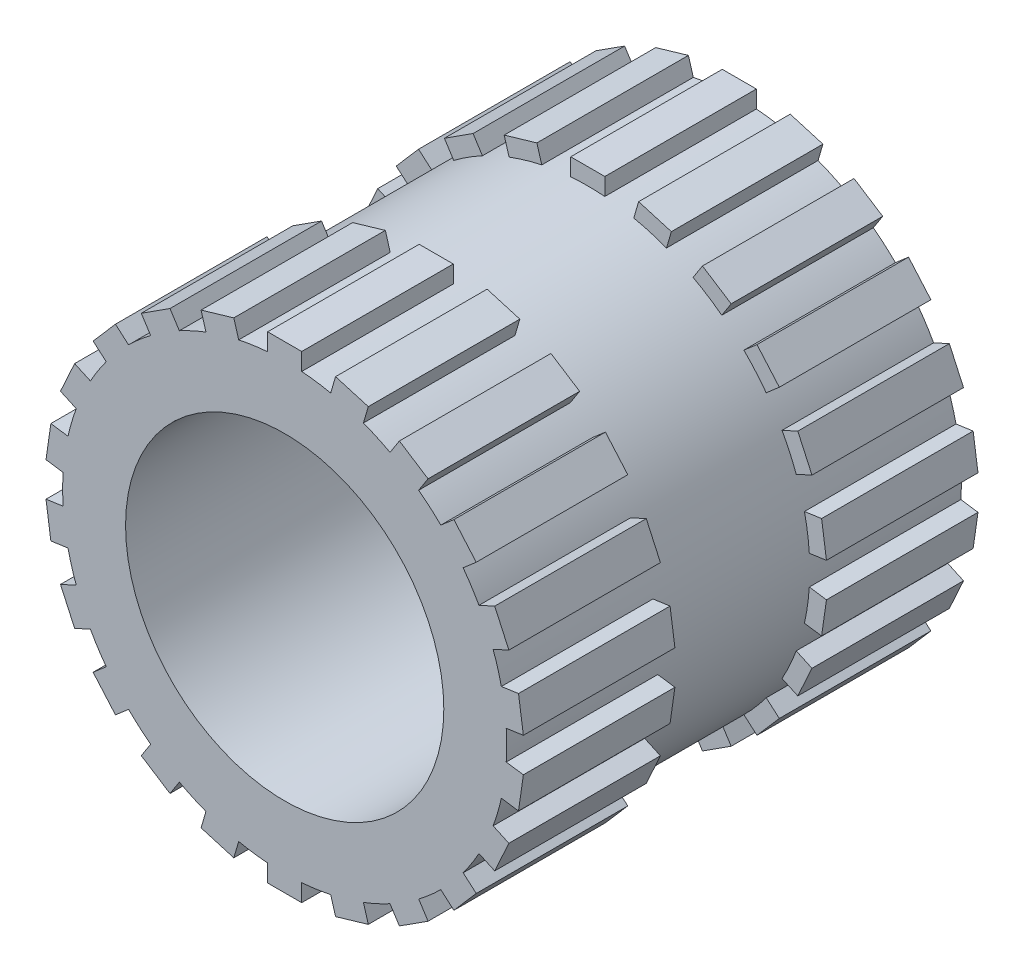
from build123d import *

# Parameters (mm, degrees)
SKETCH1_R                   = 2.93
BOSS_EXTRUDE1_DEPTH         = 3
TAP_DRILL_FOR_M5X0_8_TAP1_D = 4.2
BOSS_EXTRUDE2_DEPTH         = 2
CIRPATTERN1_COUNT           = 22
MIRROR1_COPY_1_DEPTH        = 2
MIRROR1_COPY_2_DEPTH        = 2
MIRROR1_COPY_3_DEPTH        = 2
MIRROR1_COPY_4_DEPTH        = 2
MIRROR1_COPY_5_DEPTH        = 2
MIRROR1_COPY_6_DEPTH        = 2
MIRROR1_COPY_7_DEPTH        = 2
MIRROR1_COPY_8_DEPTH        = 2
MIRROR1_COPY_9_DEPTH        = 2
MIRROR1_COPY_10_DEPTH       = 2
MIRROR1_COPY_11_DEPTH       = 2
MIRROR1_COPY_12_DEPTH       = 2
MIRROR1_COPY_13_DEPTH       = 2
MIRROR1_COPY_14_DEPTH       = 2
MIRROR1_COPY_15_DEPTH       = 2
MIRROR1_COPY_16_DEPTH       = 2
MIRROR1_COPY_17_DEPTH       = 2
MIRROR1_COPY_18_DEPTH       = 2
MIRROR1_COPY_19_DEPTH       = 2
MIRROR1_COPY_20_DEPTH       = 2
MIRROR1_COPY_21_DEPTH       = 2


with BuildPart() as part:
    # Sketch1 → Boss-Extrude1 (new body, symmetric)
    with BuildSketch(Plane.XY):
        Circle(SKETCH1_R)
    extrude(amount=BOSS_EXTRUDE1_DEPTH, both=True)

    # Tap Drill for M5x0.8 Tap1 (through all)
    with Locations(Plane.XY.offset(3)):
        with Locations((0, 0)):
            Hole(TAP_DRILL_FOR_M5X0_8_TAP1_D / 2)

    # Sketch4 → Boss-Extrude2 (add)
    with BuildSketch(Plane.XY.offset(3)):
        with BuildLine():
            Line((-0.225, 3.15), (0.225, 3.15))
            Line((0.225, 3.15), (0.225, 2.921348148))
            ThreePointArc((0.225, 2.921348148), (0, 2.93), (-0.225, 2.921348148))
            Line((-0.225, 2.921348148), (-0.225, 3.15))
        make_face()
    boss_extrude2 = extrude(amount=-BOSS_EXTRUDE2_DEPTH)

    # CirPattern1: Boss-Extrude2 ×22 about axis
    cirpattern1_axis = Axis((0, 0, 0), (0, 0, 1))
    for i in range(1, CIRPATTERN1_COUNT):
        add(boss_extrude2.rotate(cirpattern1_axis, i * 360 / CIRPATTERN1_COUNT))

    # Mirror1: Boss-Extrude2 across plane
    add(boss_extrude2.mirror(Plane.XY))

    # Mirror1 copy 1 sketch → Mirror1 copy 1 (add)
    with BuildSketch(Plane(origin=(0, 0, -3), x_dir=(0.959492974, 0.281732557, 0), z_dir=(0, 0, -1))):
        with BuildLine():
            Line((-0.225, -3.15), (0.225, -3.15))
            Line((0.225, -3.15), (0.225, -2.921348148))
            ThreePointArc((0.225, -2.921348148), (0, -2.93), (-0.225, -2.921348148))
            Line((-0.225, -2.921348148), (-0.225, -3.15))
        make_face()
    extrude(amount=-MIRROR1_COPY_1_DEPTH)

    # Mirror1 copy 2 sketch → Mirror1 copy 2 (add)
    with BuildSketch(Plane(origin=(0, 0, -3), x_dir=(0.841253533, 0.540640817, 0), z_dir=(0, 0, -1))):
        with BuildLine():
            Line((-0.225, -3.15), (0.225, -3.15))
            Line((0.225, -3.15), (0.225, -2.921348148))
            ThreePointArc((0.225, -2.921348148), (0, -2.93), (-0.225, -2.921348148))
            Line((-0.225, -2.921348148), (-0.225, -3.15))
        make_face()
    extrude(amount=-MIRROR1_COPY_2_DEPTH)

    # Mirror1 copy 3 sketch → Mirror1 copy 3 (add)
    with BuildSketch(Plane(origin=(0, 0, -3), x_dir=(0.654860734, 0.755749574, 0), z_dir=(0, 0, -1))):
        with BuildLine():
            Line((-0.225, -3.15), (0.225, -3.15))
            Line((0.225, -3.15), (0.225, -2.921348148))
            ThreePointArc((0.225, -2.921348148), (0, -2.93), (-0.225, -2.921348148))
            Line((-0.225, -2.921348148), (-0.225, -3.15))
        make_face()
    extrude(amount=-MIRROR1_COPY_3_DEPTH)

    # Mirror1 copy 4 sketch → Mirror1 copy 4 (add)
    with BuildSketch(Plane(origin=(0, 0, -3), x_dir=(0.415415013, 0.909631995, 0), z_dir=(0, 0, -1))):
        with BuildLine():
            Line((-0.225, -3.15), (0.225, -3.15))
            Line((0.225, -3.15), (0.225, -2.921348148))
            ThreePointArc((0.225, -2.921348148), (0, -2.93), (-0.225, -2.921348148))
            Line((-0.225, -2.921348148), (-0.225, -3.15))
        make_face()
    extrude(amount=-MIRROR1_COPY_4_DEPTH)

    # Mirror1 copy 5 sketch → Mirror1 copy 5 (add)
    with BuildSketch(Plane(origin=(0, 0, -3), x_dir=(0.142314838, 0.989821442, 0), z_dir=(0, 0, -1))):
        with BuildLine():
            Line((-0.225, -3.15), (0.225, -3.15))
            Line((0.225, -3.15), (0.225, -2.921348148))
            ThreePointArc((0.225, -2.921348148), (0, -2.93), (-0.225, -2.921348148))
            Line((-0.225, -2.921348148), (-0.225, -3.15))
        make_face()
    extrude(amount=-MIRROR1_COPY_5_DEPTH)

    # Mirror1 copy 6 sketch → Mirror1 copy 6 (add)
    with BuildSketch(Plane(origin=(0, 0, -3), x_dir=(-0.142314838, 0.989821442, 0), z_dir=(0, 0, -1))):
        with BuildLine():
            Line((-0.225, -3.15), (0.225, -3.15))
            Line((0.225, -3.15), (0.225, -2.921348148))
            ThreePointArc((0.225, -2.921348148), (0, -2.93), (-0.225, -2.921348148))
            Line((-0.225, -2.921348148), (-0.225, -3.15))
        make_face()
    extrude(amount=-MIRROR1_COPY_6_DEPTH)

    # Mirror1 copy 7 sketch → Mirror1 copy 7 (add)
    with BuildSketch(Plane(origin=(0, 0, -3), x_dir=(-0.415415013, 0.909631995, 0), z_dir=(0, 0, -1))):
        with BuildLine():
            Line((-0.225, -3.15), (0.225, -3.15))
            Line((0.225, -3.15), (0.225, -2.921348148))
            ThreePointArc((0.225, -2.921348148), (0, -2.93), (-0.225, -2.921348148))
            Line((-0.225, -2.921348148), (-0.225, -3.15))
        make_face()
    extrude(amount=-MIRROR1_COPY_7_DEPTH)

    # Mirror1 copy 8 sketch → Mirror1 copy 8 (add)
    with BuildSketch(Plane(origin=(0, 0, -3), x_dir=(-0.654860734, 0.755749574, 0), z_dir=(0, 0, -1))):
        with BuildLine():
            Line((-0.225, -3.15), (0.225, -3.15))
            Line((0.225, -3.15), (0.225, -2.921348148))
            ThreePointArc((0.225, -2.921348148), (0, -2.93), (-0.225, -2.921348148))
            Line((-0.225, -2.921348148), (-0.225, -3.15))
        make_face()
    extrude(amount=-MIRROR1_COPY_8_DEPTH)

    # Mirror1 copy 9 sketch → Mirror1 copy 9 (add)
    with BuildSketch(Plane(origin=(0, 0, -3), x_dir=(-0.841253533, 0.540640817, 0), z_dir=(0, 0, -1))):
        with BuildLine():
            Line((-0.225, -3.15), (0.225, -3.15))
            Line((0.225, -3.15), (0.225, -2.921348148))
            ThreePointArc((0.225, -2.921348148), (0, -2.93), (-0.225, -2.921348148))
            Line((-0.225, -2.921348148), (-0.225, -3.15))
        make_face()
    extrude(amount=-MIRROR1_COPY_9_DEPTH)

    # Mirror1 copy 10 sketch → Mirror1 copy 10 (add)
    with BuildSketch(Plane(origin=(0, 0, -3), x_dir=(-0.959492974, 0.281732557, 0), z_dir=(0, 0, -1))):
        with BuildLine():
            Line((-0.225, -3.15), (0.225, -3.15))
            Line((0.225, -3.15), (0.225, -2.921348148))
            ThreePointArc((0.225, -2.921348148), (0, -2.93), (-0.225, -2.921348148))
            Line((-0.225, -2.921348148), (-0.225, -3.15))
        make_face()
    extrude(amount=-MIRROR1_COPY_10_DEPTH)

    # Mirror1 copy 11 sketch → Mirror1 copy 11 (add)
    with BuildSketch(Plane(origin=(0, 0, -3), x_dir=(-1, 0, 0), z_dir=(0, 0, -1))):
        with BuildLine():
            Line((-0.225, -3.15), (0.225, -3.15))
            Line((0.225, -3.15), (0.225, -2.921348148))
            ThreePointArc((0.225, -2.921348148), (0, -2.93), (-0.225, -2.921348148))
            Line((-0.225, -2.921348148), (-0.225, -3.15))
        make_face()
    extrude(amount=-MIRROR1_COPY_11_DEPTH)

    # Mirror1 copy 12 sketch → Mirror1 copy 12 (add)
    with BuildSketch(Plane(origin=(0, 0, -3), x_dir=(-0.959492974, -0.281732557, 0), z_dir=(0, 0, -1))):
        with BuildLine():
            Line((-0.225, -3.15), (0.225, -3.15))
            Line((0.225, -3.15), (0.225, -2.921348148))
            ThreePointArc((0.225, -2.921348148), (0, -2.93), (-0.225, -2.921348148))
            Line((-0.225, -2.921348148), (-0.225, -3.15))
        make_face()
    extrude(amount=-MIRROR1_COPY_12_DEPTH)

    # Mirror1 copy 13 sketch → Mirror1 copy 13 (add)
    with BuildSketch(Plane(origin=(0, 0, -3), x_dir=(-0.841253533, -0.540640817, 0), z_dir=(0, 0, -1))):
        with BuildLine():
            Line((-0.225, -3.15), (0.225, -3.15))
            Line((0.225, -3.15), (0.225, -2.921348148))
            ThreePointArc((0.225, -2.921348148), (0, -2.93), (-0.225, -2.921348148))
            Line((-0.225, -2.921348148), (-0.225, -3.15))
        make_face()
    extrude(amount=-MIRROR1_COPY_13_DEPTH)

    # Mirror1 copy 14 sketch → Mirror1 copy 14 (add)
    with BuildSketch(Plane(origin=(0, 0, -3), x_dir=(-0.654860734, -0.755749574, 0), z_dir=(0, 0, -1))):
        with BuildLine():
            Line((-0.225, -3.15), (0.225, -3.15))
            Line((0.225, -3.15), (0.225, -2.921348148))
            ThreePointArc((0.225, -2.921348148), (0, -2.93), (-0.225, -2.921348148))
            Line((-0.225, -2.921348148), (-0.225, -3.15))
        make_face()
    extrude(amount=-MIRROR1_COPY_14_DEPTH)

    # Mirror1 copy 15 sketch → Mirror1 copy 15 (add)
    with BuildSketch(Plane(origin=(0, 0, -3), x_dir=(-0.415415013, -0.909631995, 0), z_dir=(0, 0, -1))):
        with BuildLine():
            Line((-0.225, -3.15), (0.225, -3.15))
            Line((0.225, -3.15), (0.225, -2.921348148))
            ThreePointArc((0.225, -2.921348148), (0, -2.93), (-0.225, -2.921348148))
            Line((-0.225, -2.921348148), (-0.225, -3.15))
        make_face()
    extrude(amount=-MIRROR1_COPY_15_DEPTH)

    # Mirror1 copy 16 sketch → Mirror1 copy 16 (add)
    with BuildSketch(Plane(origin=(0, 0, -3), x_dir=(-0.142314838, -0.989821442, 0), z_dir=(0, 0, -1))):
        with BuildLine():
            Line((-0.225, -3.15), (0.225, -3.15))
            Line((0.225, -3.15), (0.225, -2.921348148))
            ThreePointArc((0.225, -2.921348148), (0, -2.93), (-0.225, -2.921348148))
            Line((-0.225, -2.921348148), (-0.225, -3.15))
        make_face()
    extrude(amount=-MIRROR1_COPY_16_DEPTH)

    # Mirror1 copy 17 sketch → Mirror1 copy 17 (add)
    with BuildSketch(Plane(origin=(0, 0, -3), x_dir=(0.142314838, -0.989821442, 0), z_dir=(0, 0, -1))):
        with BuildLine():
            Line((-0.225, -3.15), (0.225, -3.15))
            Line((0.225, -3.15), (0.225, -2.921348148))
            ThreePointArc((0.225, -2.921348148), (0, -2.93), (-0.225, -2.921348148))
            Line((-0.225, -2.921348148), (-0.225, -3.15))
        make_face()
    extrude(amount=-MIRROR1_COPY_17_DEPTH)

    # Mirror1 copy 18 sketch → Mirror1 copy 18 (add)
    with BuildSketch(Plane(origin=(0, 0, -3), x_dir=(0.415415013, -0.909631995, 0), z_dir=(0, 0, -1))):
        with BuildLine():
            Line((-0.225, -3.15), (0.225, -3.15))
            Line((0.225, -3.15), (0.225, -2.921348148))
            ThreePointArc((0.225, -2.921348148), (0, -2.93), (-0.225, -2.921348148))
            Line((-0.225, -2.921348148), (-0.225, -3.15))
        make_face()
    extrude(amount=-MIRROR1_COPY_18_DEPTH)

    # Mirror1 copy 19 sketch → Mirror1 copy 19 (add)
    with BuildSketch(Plane(origin=(0, 0, -3), x_dir=(0.654860734, -0.755749574, 0), z_dir=(0, 0, -1))):
        with BuildLine():
            Line((-0.225, -3.15), (0.225, -3.15))
            Line((0.225, -3.15), (0.225, -2.921348148))
            ThreePointArc((0.225, -2.921348148), (0, -2.93), (-0.225, -2.921348148))
            Line((-0.225, -2.921348148), (-0.225, -3.15))
        make_face()
    extrude(amount=-MIRROR1_COPY_19_DEPTH)

    # Mirror1 copy 20 sketch → Mirror1 copy 20 (add)
    with BuildSketch(Plane(origin=(0, 0, -3), x_dir=(0.841253533, -0.540640817, 0), z_dir=(0, 0, -1))):
        with BuildLine():
            Line((-0.225, -3.15), (0.225, -3.15))
            Line((0.225, -3.15), (0.225, -2.921348148))
            ThreePointArc((0.225, -2.921348148), (0, -2.93), (-0.225, -2.921348148))
            Line((-0.225, -2.921348148), (-0.225, -3.15))
        make_face()
    extrude(amount=-MIRROR1_COPY_20_DEPTH)

    # Mirror1 copy 21 sketch → Mirror1 copy 21 (add)
    with BuildSketch(Plane(origin=(0, 0, -3), x_dir=(0.959492974, -0.281732557, 0), z_dir=(0, 0, -1))):
        with BuildLine():
            Line((-0.225, -3.15), (0.225, -3.15))
            Line((0.225, -3.15), (0.225, -2.921348148))
            ThreePointArc((0.225, -2.921348148), (0, -2.93), (-0.225, -2.921348148))
            Line((-0.225, -2.921348148), (-0.225, -3.15))
        make_face()
    extrude(amount=-MIRROR1_COPY_21_DEPTH)


solid = part.part
